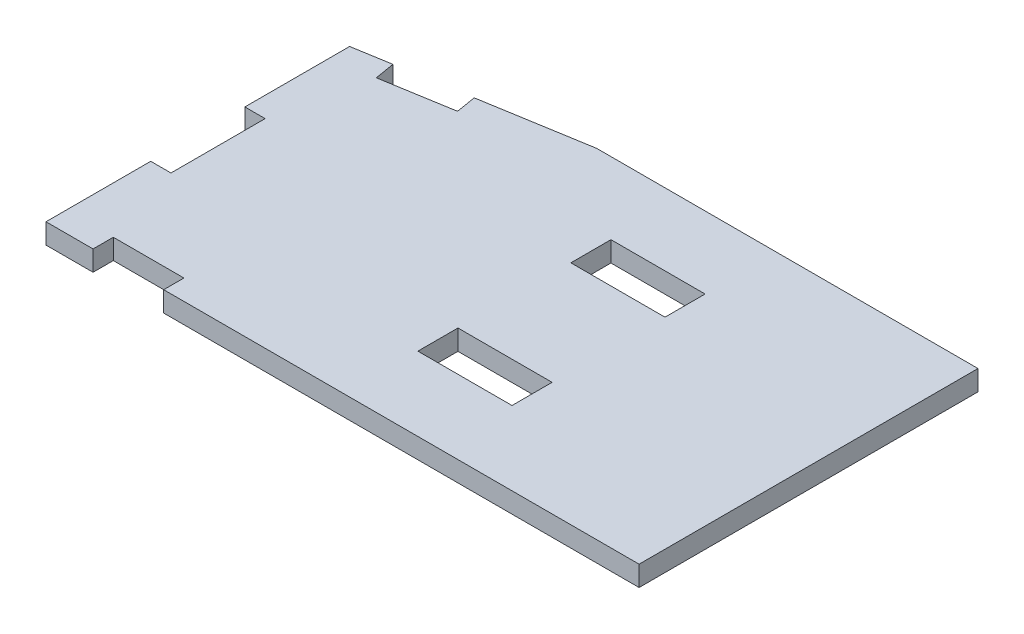
from build123d import *

# Parameters (mm, degrees)
BOSS_EXTRUDE1_DEPTH = 5.461
BOSS_EXTRUDE2_DEPTH = 5.461
SKETCH3_W           = 5.461
SKETCH3_H           = 25.4
SKETCH3_W_2         = 19.05
SKETCH3_H_2         = 5.461
CUT_EXTRUDE1_DEPTH  = 6.461
SKETCH4_W           = 25.4
SKETCH4_H           = 10.8204
CUT_EXTRUDE2_DEPTH  = 6.461


with BuildPart() as part:
    # Sketch1 → Boss-Extrude1 (new body)
    with BuildSketch(Plane(origin=(0, 0, 0), x_dir=(1, 0, 0), z_dir=(0, 1, 0))):
        Polygon((-42.3, 45.461), (-99.45, 35.936), (-99.45, -45.979), (60.57, -45.979), (60.57, 45.461), align=None)
        with BuildLine():
            ThreePointArc((-55, 32.5), (-52.803300859, 37.803300859), (-47.5, 40))
            Line((-47.5, 40), (47.5, 40))
            ThreePointArc((47.5, 40), (52.803300859, 37.803300859), (55, 32.5))
            Line((55, 32.5), (55, -32.5))
            ThreePointArc((55, -32.5), (52.803300859, -37.803300859), (47.5, -40))
            Line((47.5, -40), (-47.5, -40))
            ThreePointArc((-47.5, -40), (-52.803300859, -37.803300859), (-55, -32.5))
            Line((-55, -32.5), (-55, 32.5))
        make_face(mode=Mode.SUBTRACT)
    extrude(amount=BOSS_EXTRUDE1_DEPTH)

    # Sketch2 → Boss-Extrude2 (add)
    with BuildSketch(Plane(origin=(0, 5.461, 0), x_dir=(1, 0, 0), z_dir=(0, 1, 0))):
        with BuildLine():
            Line((-47.5, -40), (47.5, -40))
            ThreePointArc((47.5, -40), (52.803300859, -37.803300859), (55, -32.5))
            Line((55, -32.5), (55, 32.5))
            ThreePointArc((55, 32.5), (52.803300859, 37.803300859), (47.5, 40))
            Line((47.5, 40), (-47.5, 40))
            ThreePointArc((-47.5, 40), (-52.803300859, 37.803300859), (-55, 32.5))
            Line((-55, 32.5), (-55, -32.5))
            ThreePointArc((-55, -32.5), (-52.803300859, -37.803300859), (-47.5, -40))
        make_face()
    extrude(amount=-BOSS_EXTRUDE2_DEPTH)

    # Sketch3 → Cut-Extrude1 (cut, through all)
    with BuildSketch(Plane.XZ):
        Polygon((-70.637433485, -40.738094419), (-89.428237734, -37.606293711), (-88.530454864, -32.219596493), (-69.739650615, -35.351397201), align=None)
        with Locations((-96.7195, 5.0215)):
            Rectangle(SKETCH3_W, SKETCH3_H)
        with Locations((-77.225, 43.2485)):
            Rectangle(SKETCH3_W_2, SKETCH3_H_2)
    extrude(amount=-CUT_EXTRUDE1_DEPTH, mode=Mode.SUBTRACT)

    # Sketch4 → Cut-Extrude2 (cut, through all)
    with BuildSketch(Plane(origin=(0, 5.461, 0), x_dir=(1, 0, 0), z_dir=(0, 1, 0))):
        with Locations((-6.35, -20.6375)):
            Rectangle(SKETCH4_W, SKETCH4_H)
        with Locations((-6.35, 20.6375)):
            Rectangle(SKETCH4_W, SKETCH4_H)
    extrude(amount=-CUT_EXTRUDE2_DEPTH, mode=Mode.SUBTRACT)


solid = part.part
